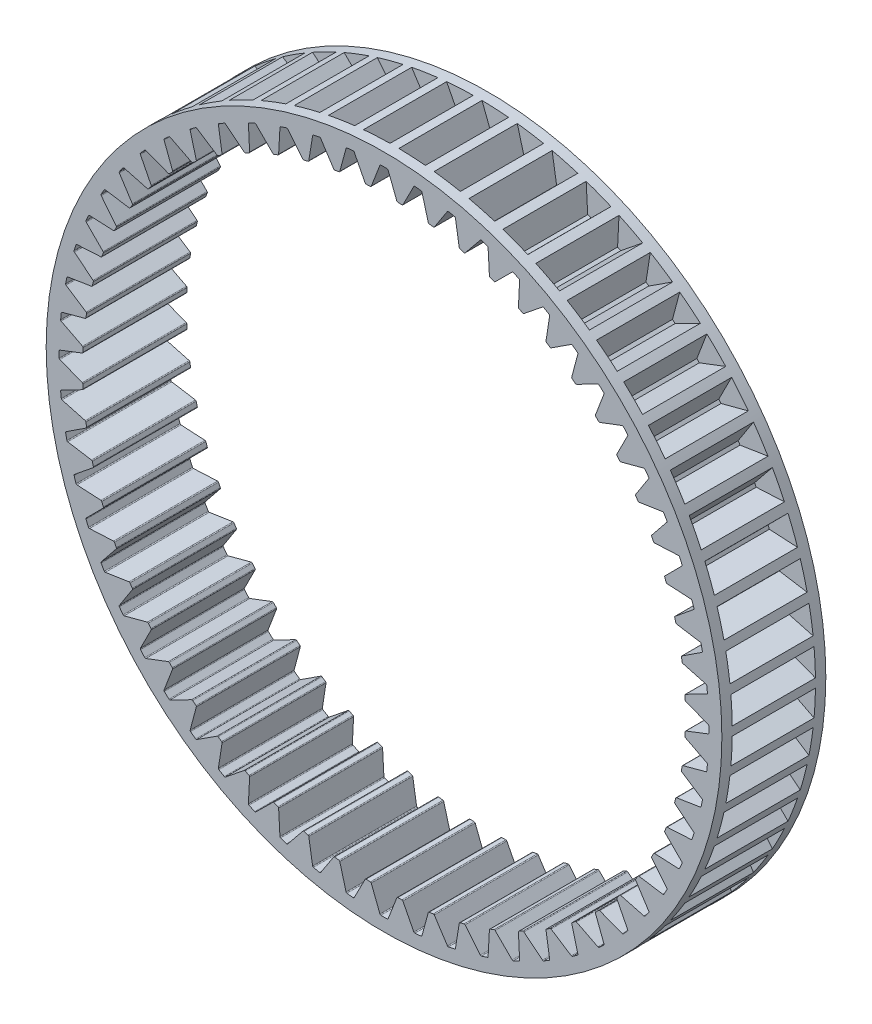
from build123d import *

# Parameters (mm, degrees)
SKETCH1_R           = 32.5
BOSS_EXTRUDE1_DEPTH = 10
CUT_EXTRUDE9_DEPTH  = 8
CIRPATTERN2_COUNT   = 60


with BuildPart() as part:
    # Sketch1 → Boss-Extrude1 (new body)
    with BuildSketch(Plane.XY):
        Circle(SKETCH1_R)
        with BuildLine():
            Line((-1.22642736, 29.033979374), (-0.394405156, 31.184625414))
            ThreePointArc((-0.394405156, 31.184625414), (-0.358072014, 31.230756791), (-0.302108, 31.248539658))
            ThreePointArc((-0.302108, 31.248539658), (0, 31.25), (0.302108, 31.248539658))
            ThreePointArc((0.302108, 31.248539658), (0.358072014, 31.230756791), (0.394405156, 31.184625414))
            Line((0.394405156, 31.184625414), (1.22642736, 29.033979374))
            ThreePointArc((1.22642736, 29.033979374), (1.261302231, 28.988877201), (1.31515624, 28.970163342))
            ThreePointArc((1.31515624, 28.970163342), (1.517742731, 28.960256508), (1.720254978, 28.948933017))
            ThreePointArc((1.720254978, 28.948933017), (1.7757701, 28.961915082), (1.815168384, 29.003124765))
            Line((1.815168384, 29.003124765), (2.867436409, 31.055019338))
            ThreePointArc((2.867436409, 31.055019338), (2.908392556, 31.097100155), (2.96590881, 31.108935773))
            ThreePointArc((2.96590881, 31.108935773), (3.266514477, 31.07880923), (3.56681485, 31.045778003))
            ThreePointArc((3.56681485, 31.045778003), (3.620613472, 31.02224272), (3.651925536, 30.972566208))
            Line((3.651925536, 30.972566208), (4.254586109, 28.74673163))
            ThreePointArc((4.254586109, 28.74673163), (4.284555471, 28.698231114), (4.336158332, 28.673990495))
            ThreePointArc((4.336158332, 28.673990495), (4.536599486, 28.642961877), (4.736818723, 28.610532123))
            ThreePointArc((4.736818723, 28.610532123), (4.793386722, 28.617640161), (4.836876764, 28.654505851))
            Line((4.836876764, 28.654505851), (6.09786174, 30.585167971))
            ThreePointArc((6.09786174, 30.585167971), (6.142992169, 30.622737182), (6.201430501, 30.628495878))
            ThreePointArc((6.201430501, 30.628495878), (6.497240338, 30.567112523), (6.792442931, 30.502872308))
            ThreePointArc((6.792442931, 30.502872308), (6.843486731, 30.473842467), (6.869434655, 30.421165085))
            Line((6.869434655, 30.421165085), (7.236130722, 28.144528679))
            ThreePointArc((7.236130722, 28.144528679), (7.260866225, 28.093161202), (7.309652565, 28.063659408))
            ThreePointArc((7.309652565, 28.063659408), (7.505752308, 28.011848962), (7.70148489, 27.958668253))
            ThreePointArc((7.70148489, 27.958668253), (7.758485997, 27.959824386), (7.805591309, 27.991942174))
            Line((7.805591309, 27.991942174), (9.261477622, 29.780219104))
            ThreePointArc((9.261477622, 29.780219104), (9.310287874, 29.812865092), (9.369008022, 29.812483772))
            ThreePointArc((9.369008022, 29.812483772), (9.656781074, 29.720516134), (9.943651585, 29.62577076))
            ThreePointArc((9.943651585, 29.62577076), (9.991381318, 29.591564418), (10.01168081, 29.536463312))
            Line((10.01168081, 29.536463312), (10.138394773, 27.233968381))
            ThreePointArc((10.138394773, 27.233968381), (10.157625409, 27.180296737), (10.203060715, 27.145856996))
            ThreePointArc((10.203060715, 27.145856996), (10.392670537, 27.073832368), (10.581771978, 27.000483363))
            ThreePointArc((10.581771978, 27.000483363), (10.638581675, 26.995674924), (10.688786162, 27.022692922))
            Line((10.688786162, 27.022692922), (12.323622817, 28.648991924))
            ThreePointArc((12.323622817, 28.648991924), (12.375578116, 28.676357014), (12.433936731, 28.669839856))
            ThreePointArc((12.433936731, 28.669839856), (12.710520096, 28.548295551), (12.985915512, 28.424083069))
            ThreePointArc((12.985915512, 28.424083069), (13.02980824, 28.385074996), (13.044236895, 28.328153866))
            Line((13.044236895, 28.328153866), (12.929580449, 26.025027028))
            ThreePointArc((12.929580449, 26.025027028), (12.943095523, 25.969639253), (12.984681997, 25.930638894))
            ThreePointArc((12.984681997, 25.930638894), (13.165724492, 25.839189201), (13.346122957, 25.746475526))
            ThreePointArc((13.346122957, 25.746475526), (13.402118826, 25.735755199), (13.454872438, 25.757377391))
            Line((13.454872438, 25.757377391), (15.250747822, 27.203880394))
            ThreePointArc((15.250747822, 27.203880394), (15.305278935, 27.225664767), (15.362636627, 27.213083175))
            ThreePointArc((15.362636627, 27.213083175), (15.625, 27.063293868), (15.885903031, 26.910975175))
            ThreePointArc((15.885903031, 26.910975175), (15.925477856, 26.867592754), (15.933877592, 26.809475238))
            Line((15.933877592, 26.809475238), (15.579106936, 24.530950031))
            ThreePointArc((15.579106936, 24.530950031), (15.586758375, 24.474452967), (15.624040385, 24.431319286))
            ThreePointArc((15.624040385, 24.431319286), (15.794532015, 24.32144647), (15.96425102, 24.210383916))
            ThreePointArc((15.96425102, 24.210383916), (16.018819559, 24.193869153), (16.073544315, 24.209858643))
            Line((16.073544315, 24.209858643), (18.010782442, 25.460717457))
            ThreePointArc((18.010782442, 25.460717457), (18.067291916, 25.47668244), (18.123020261, 25.458174259))
            ThreePointArc((18.123020261, 25.458174259), (18.368289134, 25.281781074), (18.611841272, 25.103025006))
            ThreePointArc((18.611841272, 25.103025006), (18.646664604, 25.055743542), (18.648943391, 24.997066389))
            Line((18.648943391, 24.997066389), (18.057945468, 22.768106813))
            ThreePointArc((18.057945468, 22.768106813), (18.059649439, 22.711119453), (18.092218518, 22.664325031))
            ThreePointArc((18.092218518, 22.664325031), (18.25029134, 22.537232882), (18.407471409, 22.409038273))
            ThreePointArc((18.407471409, 22.409038273), (18.460014752, 22.386910015), (18.516111078, 22.397091618))
            Line((18.516111078, 22.397091618), (20.573487161, 23.438601572))
            ThreePointArc((20.573487161, 23.438601572), (20.631355865, 23.448572249), (20.684844293, 23.424340259))
            ThreePointArc((20.684844293, 23.424340259), (20.910331449, 23.223275796), (21.133864286, 23.020040842))
            ThreePointArc((21.133864286, 23.020040842), (21.163554593, 22.969378361), (21.159687463, 22.910784449))
            Line((21.159687463, 22.910784449), (20.33893737, 20.755811452))
            ThreePointArc((20.33893737, 20.755811452), (20.334675206, 20.698958161), (20.362174518, 20.649015688))
            ThreePointArc((20.362174518, 20.649015688), (20.506096654, 20.506096654), (20.649015688, 20.362174518))
            ThreePointArc((20.649015688, 20.362174518), (20.698958161, 20.334675206), (20.755811452, 20.33893737))
            Line((20.755811452, 20.33893737), (22.910784449, 21.159687463))
            ThreePointArc((22.910784449, 21.159687463), (22.969378361, 21.163554593), (23.020040842, 21.133864286))
            ThreePointArc((23.020040842, 21.133864286), (23.223275796, 20.910331449), (23.424340259, 20.684844293))
            ThreePointArc((23.424340259, 20.684844293), (23.448572249, 20.631355865), (23.438601572, 20.573487161))
            Line((23.438601572, 20.573487161), (22.397091618, 18.516111078))
            ThreePointArc((22.397091618, 18.516111078), (22.386910015, 18.460014752), (22.409038273, 18.407471409))
            ThreePointArc((22.409038273, 18.407471409), (22.537232882, 18.25029134), (22.664325031, 18.092218518))
            ThreePointArc((22.664325031, 18.092218518), (22.711119453, 18.059649439), (22.768106813, 18.057945468))
            Line((22.768106813, 18.057945468), (24.997066389, 18.648943391))
            ThreePointArc((24.997066389, 18.648943391), (25.055743542, 18.646664604), (25.103025006, 18.611841272))
            ThreePointArc((25.103025006, 18.611841272), (25.281781074, 18.368289134), (25.458174259, 18.123020261))
            ThreePointArc((25.458174259, 18.123020261), (25.47668244, 18.067291916), (25.460717457, 18.010782442))
            Line((25.460717457, 18.010782442), (24.209858643, 16.073544315))
            ThreePointArc((24.209858643, 16.073544315), (24.193869153, 16.018819559), (24.210383916, 15.96425102))
            ThreePointArc((24.210383916, 15.96425102), (24.32144647, 15.794532015), (24.431319286, 15.624040385))
            ThreePointArc((24.431319286, 15.624040385), (24.474452967, 15.586758375), (24.530950031, 15.579106936))
            Line((24.530950031, 15.579106936), (26.809475238, 15.933877592))
            ThreePointArc((26.809475238, 15.933877592), (26.867592754, 15.925477856), (26.910975175, 15.885903031))
            ThreePointArc((26.910975175, 15.885903031), (27.063293868, 15.625), (27.213083175, 15.362636627))
            ThreePointArc((27.213083175, 15.362636627), (27.225664767, 15.305278935), (27.203880394, 15.250747822))
            Line((27.203880394, 15.250747822), (25.757377391, 13.454872438))
            ThreePointArc((25.757377391, 13.454872438), (25.735755199, 13.402118826), (25.746475526, 13.346122957))
            ThreePointArc((25.746475526, 13.346122957), (25.839189201, 13.165724492), (25.930638894, 12.984681997))
            ThreePointArc((25.930638894, 12.984681997), (25.969639253, 12.943095523), (26.025027028, 12.929580449))
            Line((26.025027028, 12.929580449), (28.328153866, 13.044236895))
            ThreePointArc((28.328153866, 13.044236895), (28.385074996, 13.02980824), (28.424083069, 12.985915512))
            ThreePointArc((28.424083069, 12.985915512), (28.548295551, 12.710520096), (28.669839856, 12.433936731))
            ThreePointArc((28.669839856, 12.433936731), (28.676357014, 12.375578116), (28.648991924, 12.323622817))
            Line((28.648991924, 12.323622817), (27.022692922, 10.688786162))
            ThreePointArc((27.022692922, 10.688786162), (26.995674924, 10.638581675), (27.000483363, 10.581771978))
            ThreePointArc((27.000483363, 10.581771978), (27.073832368, 10.392670537), (27.145856996, 10.203060715))
            ThreePointArc((27.145856996, 10.203060715), (27.180296737, 10.157625409), (27.233968381, 10.138394773))
            Line((27.233968381, 10.138394773), (29.536463312, 10.01168081))
            ThreePointArc((29.536463312, 10.01168081), (29.591564418, 9.991381318), (29.62577076, 9.943651585))
            ThreePointArc((29.62577076, 9.943651585), (29.720516134, 9.656781074), (29.812483772, 9.369008022))
            ThreePointArc((29.812483772, 9.369008022), (29.812865092, 9.310287874), (29.780219104, 9.261477622))
            Line((29.780219104, 9.261477622), (27.991942174, 7.805591309))
            ThreePointArc((27.991942174, 7.805591309), (27.959824386, 7.758485997), (27.958668253, 7.70148489))
            ThreePointArc((27.958668253, 7.70148489), (28.011848962, 7.505752308), (28.063659408, 7.309652565))
            ThreePointArc((28.063659408, 7.309652565), (28.093161202, 7.260866225), (28.144528679, 7.236130722))
            Line((28.144528679, 7.236130722), (30.421165085, 6.869434655))
            ThreePointArc((30.421165085, 6.869434655), (30.473842467, 6.843486731), (30.502872308, 6.792442931))
            ThreePointArc((30.502872308, 6.792442931), (30.567112523, 6.497240338), (30.628495878, 6.201430501))
            ThreePointArc((30.628495878, 6.201430501), (30.622737182, 6.142992169), (30.585167971, 6.09786174))
            Line((30.585167971, 6.09786174), (28.654505851, 4.836876764))
            ThreePointArc((28.654505851, 4.836876764), (28.617640161, 4.793386722), (28.610532123, 4.736818723))
            ThreePointArc((28.610532123, 4.736818723), (28.642961877, 4.536599486), (28.673990495, 4.336158332))
            ThreePointArc((28.673990495, 4.336158332), (28.698231114, 4.284555471), (28.74673163, 4.254586109))
            Line((28.74673163, 4.254586109), (30.972566208, 3.651925536))
            ThreePointArc((30.972566208, 3.651925536), (31.02224272, 3.620613472), (31.045778003, 3.56681485))
            ThreePointArc((31.045778003, 3.56681485), (31.07880923, 3.266514477), (31.108935773, 2.96590881))
            ThreePointArc((31.108935773, 2.96590881), (31.097100155, 2.908392556), (31.055019338, 2.867436409))
            Line((31.055019338, 2.867436409), (29.003124765, 1.815168384))
            ThreePointArc((29.003124765, 1.815168384), (28.961915082, 1.7757701), (28.948933017, 1.720254978))
            ThreePointArc((28.948933017, 1.720254978), (28.960256508, 1.517742731), (28.970163342, 1.31515624))
            ThreePointArc((28.970163342, 1.31515624), (28.988877201, 1.261302231), (29.033979374, 1.22642736))
            Line((29.033979374, 1.22642736), (31.184625414, 0.394405156))
            ThreePointArc((31.184625414, 0.394405156), (31.230756791, 0.358072014), (31.248539658, 0.302108))
            ThreePointArc((31.248539658, 0.302108), (31.25, 0), (31.248539658, -0.302108))
            ThreePointArc((31.248539658, -0.302108), (31.230756791, -0.358072014), (31.184625414, -0.394405156))
            Line((31.184625414, -0.394405156), (29.033979374, -1.22642736))
            ThreePointArc((29.033979374, -1.22642736), (28.988877201, -1.261302231), (28.970163342, -1.31515624))
            ThreePointArc((28.970163342, -1.31515624), (28.960256508, -1.517742731), (28.948933017, -1.720254978))
            ThreePointArc((28.948933017, -1.720254978), (28.961915082, -1.7757701), (29.003124765, -1.815168384))
            Line((29.003124765, -1.815168384), (31.055019338, -2.867436409))
            ThreePointArc((31.055019338, -2.867436409), (31.097100155, -2.908392556), (31.108935773, -2.96590881))
            ThreePointArc((31.108935773, -2.96590881), (31.07880923, -3.266514477), (31.045778003, -3.56681485))
            ThreePointArc((31.045778003, -3.56681485), (31.02224272, -3.620613472), (30.972566208, -3.651925536))
            Line((30.972566208, -3.651925536), (28.74673163, -4.254586109))
            ThreePointArc((28.74673163, -4.254586109), (28.698231114, -4.284555471), (28.673990495, -4.336158332))
            ThreePointArc((28.673990495, -4.336158332), (28.642961877, -4.536599486), (28.610532123, -4.736818723))
            ThreePointArc((28.610532123, -4.736818723), (28.617640161, -4.793386722), (28.654505851, -4.836876764))
            Line((28.654505851, -4.836876764), (30.585167971, -6.09786174))
            ThreePointArc((30.585167971, -6.09786174), (30.622737182, -6.142992169), (30.628495878, -6.201430501))
            ThreePointArc((30.628495878, -6.201430501), (30.567112523, -6.497240338), (30.502872308, -6.792442931))
            ThreePointArc((30.502872308, -6.792442931), (30.473842467, -6.843486731), (30.421165085, -6.869434655))
            Line((30.421165085, -6.869434655), (28.144528679, -7.236130722))
            ThreePointArc((28.144528679, -7.236130722), (28.093161202, -7.260866225), (28.063659408, -7.309652565))
            ThreePointArc((28.063659408, -7.309652565), (28.011848962, -7.505752308), (27.958668253, -7.70148489))
            ThreePointArc((27.958668253, -7.70148489), (27.959824386, -7.758485997), (27.991942174, -7.805591309))
            Line((27.991942174, -7.805591309), (29.780219104, -9.261477622))
            ThreePointArc((29.780219104, -9.261477622), (29.812865092, -9.310287874), (29.812483772, -9.369008022))
            ThreePointArc((29.812483772, -9.369008022), (29.720516134, -9.656781074), (29.62577076, -9.943651585))
            ThreePointArc((29.62577076, -9.943651585), (29.591564418, -9.991381318), (29.536463312, -10.01168081))
            Line((29.536463312, -10.01168081), (27.233968381, -10.138394773))
            ThreePointArc((27.233968381, -10.138394773), (27.180296737, -10.157625409), (27.145856996, -10.203060715))
            ThreePointArc((27.145856996, -10.203060715), (27.073832368, -10.392670537), (27.000483363, -10.581771978))
            ThreePointArc((27.000483363, -10.581771978), (26.995674924, -10.638581675), (27.022692922, -10.688786162))
            Line((27.022692922, -10.688786162), (28.648991924, -12.323622817))
            ThreePointArc((28.648991924, -12.323622817), (28.676357014, -12.375578116), (28.669839856, -12.433936731))
            ThreePointArc((28.669839856, -12.433936731), (28.548295551, -12.710520096), (28.424083069, -12.985915512))
            ThreePointArc((28.424083069, -12.985915512), (28.385074996, -13.02980824), (28.328153866, -13.044236895))
            Line((28.328153866, -13.044236895), (26.025027028, -12.929580449))
            ThreePointArc((26.025027028, -12.929580449), (25.969639253, -12.943095523), (25.930638894, -12.984681997))
            ThreePointArc((25.930638894, -12.984681997), (25.839189201, -13.165724492), (25.746475526, -13.346122957))
            ThreePointArc((25.746475526, -13.346122957), (25.735755199, -13.402118826), (25.757377391, -13.454872438))
            Line((25.757377391, -13.454872438), (27.203880394, -15.250747822))
            ThreePointArc((27.203880394, -15.250747822), (27.225664767, -15.305278935), (27.213083175, -15.362636627))
            ThreePointArc((27.213083175, -15.362636627), (27.063293868, -15.625), (26.910975175, -15.885903031))
            ThreePointArc((26.910975175, -15.885903031), (26.867592754, -15.925477856), (26.809475238, -15.933877592))
            Line((26.809475238, -15.933877592), (24.530950031, -15.579106936))
            ThreePointArc((24.530950031, -15.579106936), (24.474452967, -15.586758375), (24.431319286, -15.624040385))
            ThreePointArc((24.431319286, -15.624040385), (24.32144647, -15.794532015), (24.210383916, -15.96425102))
            ThreePointArc((24.210383916, -15.96425102), (24.193869153, -16.018819559), (24.209858643, -16.073544315))
            Line((24.209858643, -16.073544315), (25.460717457, -18.010782442))
            ThreePointArc((25.460717457, -18.010782442), (25.47668244, -18.067291916), (25.458174259, -18.123020261))
            ThreePointArc((25.458174259, -18.123020261), (25.281781074, -18.368289134), (25.103025006, -18.611841272))
            ThreePointArc((25.103025006, -18.611841272), (25.055743542, -18.646664604), (24.997066389, -18.648943391))
            Line((24.997066389, -18.648943391), (22.768106813, -18.057945468))
            ThreePointArc((22.768106813, -18.057945468), (22.711119453, -18.059649439), (22.664325031, -18.092218518))
            ThreePointArc((22.664325031, -18.092218518), (22.537232882, -18.25029134), (22.409038273, -18.407471409))
            ThreePointArc((22.409038273, -18.407471409), (22.386910015, -18.460014752), (22.397091618, -18.516111078))
            Line((22.397091618, -18.516111078), (23.438601572, -20.573487161))
            ThreePointArc((23.438601572, -20.573487161), (23.448572249, -20.631355865), (23.424340259, -20.684844293))
            ThreePointArc((23.424340259, -20.684844293), (23.223275796, -20.910331449), (23.020040842, -21.133864286))
            ThreePointArc((23.020040842, -21.133864286), (22.969378361, -21.163554593), (22.910784449, -21.159687463))
            Line((22.910784449, -21.159687463), (20.755811452, -20.33893737))
            ThreePointArc((20.755811452, -20.33893737), (20.698958161, -20.334675206), (20.649015688, -20.362174518))
            ThreePointArc((20.649015688, -20.362174518), (20.506096654, -20.506096654), (20.362174518, -20.649015688))
            ThreePointArc((20.362174518, -20.649015688), (20.334675206, -20.698958161), (20.33893737, -20.755811452))
            Line((20.33893737, -20.755811452), (21.159687463, -22.910784449))
            ThreePointArc((21.159687463, -22.910784449), (21.163554593, -22.969378361), (21.133864286, -23.020040842))
            ThreePointArc((21.133864286, -23.020040842), (20.910331449, -23.223275796), (20.684844293, -23.424340259))
            ThreePointArc((20.684844293, -23.424340259), (20.631355865, -23.448572249), (20.573487161, -23.438601572))
            Line((20.573487161, -23.438601572), (18.516111078, -22.397091618))
            ThreePointArc((18.516111078, -22.397091618), (18.460014752, -22.386910015), (18.407471409, -22.409038273))
            ThreePointArc((18.407471409, -22.409038273), (18.25029134, -22.537232882), (18.092218518, -22.664325031))
            ThreePointArc((18.092218518, -22.664325031), (18.059649439, -22.711119453), (18.057945468, -22.768106813))
            Line((18.057945468, -22.768106813), (18.648943391, -24.997066389))
            ThreePointArc((18.648943391, -24.997066389), (18.646664604, -25.055743542), (18.611841272, -25.103025006))
            ThreePointArc((18.611841272, -25.103025006), (18.368289134, -25.281781074), (18.123020261, -25.458174259))
            ThreePointArc((18.123020261, -25.458174259), (18.067291916, -25.47668244), (18.010782442, -25.460717457))
            Line((18.010782442, -25.460717457), (16.073544315, -24.209858643))
            ThreePointArc((16.073544315, -24.209858643), (16.018819559, -24.193869153), (15.96425102, -24.210383916))
            ThreePointArc((15.96425102, -24.210383916), (15.794532015, -24.32144647), (15.624040385, -24.431319286))
            ThreePointArc((15.624040385, -24.431319286), (15.586758375, -24.474452967), (15.579106936, -24.530950031))
            Line((15.579106936, -24.530950031), (15.933877592, -26.809475238))
            ThreePointArc((15.933877592, -26.809475238), (15.925477856, -26.867592754), (15.885903031, -26.910975175))
            ThreePointArc((15.885903031, -26.910975175), (15.625, -27.063293868), (15.362636627, -27.213083175))
            ThreePointArc((15.362636627, -27.213083175), (15.305278935, -27.225664767), (15.250747822, -27.203880394))
            Line((15.250747822, -27.203880394), (13.454872438, -25.757377391))
            ThreePointArc((13.454872438, -25.757377391), (13.402118826, -25.735755199), (13.346122957, -25.746475526))
            ThreePointArc((13.346122957, -25.746475526), (13.165724492, -25.839189201), (12.984681997, -25.930638894))
            ThreePointArc((12.984681997, -25.930638894), (12.943095523, -25.969639253), (12.929580449, -26.025027028))
            Line((12.929580449, -26.025027028), (13.044236895, -28.328153866))
            ThreePointArc((13.044236895, -28.328153866), (13.02980824, -28.385074996), (12.985915512, -28.424083069))
            ThreePointArc((12.985915512, -28.424083069), (12.710520096, -28.548295551), (12.433936731, -28.669839856))
            ThreePointArc((12.433936731, -28.669839856), (12.375578116, -28.676357014), (12.323622817, -28.648991924))
            Line((12.323622817, -28.648991924), (10.688786162, -27.022692922))
            ThreePointArc((10.688786162, -27.022692922), (10.638581675, -26.995674924), (10.581771978, -27.000483363))
            ThreePointArc((10.581771978, -27.000483363), (10.392670537, -27.073832368), (10.203060715, -27.145856996))
            ThreePointArc((10.203060715, -27.145856996), (10.157625409, -27.180296737), (10.138394773, -27.233968381))
            Line((10.138394773, -27.233968381), (10.01168081, -29.536463312))
            ThreePointArc((10.01168081, -29.536463312), (9.991381318, -29.591564418), (9.943651585, -29.62577076))
            ThreePointArc((9.943651585, -29.62577076), (9.656781074, -29.720516134), (9.369008022, -29.812483772))
            ThreePointArc((9.369008022, -29.812483772), (9.310287874, -29.812865092), (9.261477622, -29.780219104))
            Line((9.261477622, -29.780219104), (7.805591309, -27.991942174))
            ThreePointArc((7.805591309, -27.991942174), (7.758485997, -27.959824386), (7.70148489, -27.958668253))
            ThreePointArc((7.70148489, -27.958668253), (7.505752308, -28.011848962), (7.309652565, -28.063659408))
            ThreePointArc((7.309652565, -28.063659408), (7.260866225, -28.093161202), (7.236130722, -28.144528679))
            Line((7.236130722, -28.144528679), (6.869434655, -30.421165085))
            ThreePointArc((6.869434655, -30.421165085), (6.843486731, -30.473842467), (6.792442931, -30.502872308))
            ThreePointArc((6.792442931, -30.502872308), (6.497240338, -30.567112523), (6.201430501, -30.628495878))
            ThreePointArc((6.201430501, -30.628495878), (6.142992169, -30.622737182), (6.09786174, -30.585167971))
            Line((6.09786174, -30.585167971), (4.836876764, -28.654505851))
            ThreePointArc((4.836876764, -28.654505851), (4.793386722, -28.617640161), (4.736818723, -28.610532123))
            ThreePointArc((4.736818723, -28.610532123), (4.536599486, -28.642961877), (4.336158332, -28.673990495))
            ThreePointArc((4.336158332, -28.673990495), (4.284555471, -28.698231114), (4.254586109, -28.74673163))
            Line((4.254586109, -28.74673163), (3.651925536, -30.972566208))
            ThreePointArc((3.651925536, -30.972566208), (3.620613472, -31.02224272), (3.56681485, -31.045778003))
            ThreePointArc((3.56681485, -31.045778003), (3.266514477, -31.07880923), (2.96590881, -31.108935773))
            ThreePointArc((2.96590881, -31.108935773), (2.908392556, -31.097100155), (2.867436409, -31.055019338))
            Line((2.867436409, -31.055019338), (1.815168384, -29.003124765))
            ThreePointArc((1.815168384, -29.003124765), (1.7757701, -28.961915082), (1.720254978, -28.948933017))
            ThreePointArc((1.720254978, -28.948933017), (1.517742731, -28.960256508), (1.31515624, -28.970163342))
            ThreePointArc((1.31515624, -28.970163342), (1.261302231, -28.988877201), (1.22642736, -29.033979374))
            Line((1.22642736, -29.033979374), (0.394405156, -31.184625414))
            ThreePointArc((0.394405156, -31.184625414), (0.358072014, -31.230756791), (0.302108, -31.248539658))
            ThreePointArc((0.302108, -31.248539658), (0, -31.25), (-0.302108, -31.248539658))
            ThreePointArc((-0.302108, -31.248539658), (-0.358072014, -31.230756791), (-0.394405156, -31.184625414))
            Line((-0.394405156, -31.184625414), (-1.22642736, -29.033979374))
            ThreePointArc((-1.22642736, -29.033979374), (-1.261302231, -28.988877201), (-1.31515624, -28.970163342))
            ThreePointArc((-1.31515624, -28.970163342), (-1.517742731, -28.960256508), (-1.720254978, -28.948933017))
            ThreePointArc((-1.720254978, -28.948933017), (-1.7757701, -28.961915082), (-1.815168384, -29.003124765))
            Line((-1.815168384, -29.003124765), (-2.867436409, -31.055019338))
            ThreePointArc((-2.867436409, -31.055019338), (-2.908392556, -31.097100155), (-2.96590881, -31.108935773))
            ThreePointArc((-2.96590881, -31.108935773), (-3.266514477, -31.07880923), (-3.56681485, -31.045778003))
            ThreePointArc((-3.56681485, -31.045778003), (-3.620613472, -31.02224272), (-3.651925536, -30.972566208))
            Line((-3.651925536, -30.972566208), (-4.254586109, -28.74673163))
            ThreePointArc((-4.254586109, -28.74673163), (-4.284555471, -28.698231114), (-4.336158332, -28.673990495))
            ThreePointArc((-4.336158332, -28.673990495), (-4.536599486, -28.642961877), (-4.736818723, -28.610532123))
            ThreePointArc((-4.736818723, -28.610532123), (-4.793386722, -28.617640161), (-4.836876764, -28.654505851))
            Line((-4.836876764, -28.654505851), (-6.09786174, -30.585167971))
            ThreePointArc((-6.09786174, -30.585167971), (-6.142992169, -30.622737182), (-6.201430501, -30.628495878))
            ThreePointArc((-6.201430501, -30.628495878), (-6.497240338, -30.567112523), (-6.792442931, -30.502872308))
            ThreePointArc((-6.792442931, -30.502872308), (-6.843486731, -30.473842467), (-6.869434655, -30.421165085))
            Line((-6.869434655, -30.421165085), (-7.236130722, -28.144528679))
            ThreePointArc((-7.236130722, -28.144528679), (-7.260866225, -28.093161202), (-7.309652565, -28.063659408))
            ThreePointArc((-7.309652565, -28.063659408), (-7.505752308, -28.011848962), (-7.70148489, -27.958668253))
            ThreePointArc((-7.70148489, -27.958668253), (-7.758485997, -27.959824386), (-7.805591309, -27.991942174))
            Line((-7.805591309, -27.991942174), (-9.261477622, -29.780219104))
            ThreePointArc((-9.261477622, -29.780219104), (-9.310287874, -29.812865092), (-9.369008022, -29.812483772))
            ThreePointArc((-9.369008022, -29.812483772), (-9.656781074, -29.720516134), (-9.943651585, -29.62577076))
            ThreePointArc((-9.943651585, -29.62577076), (-9.991381318, -29.591564418), (-10.01168081, -29.536463312))
            Line((-10.01168081, -29.536463312), (-10.138394773, -27.233968381))
            ThreePointArc((-10.138394773, -27.233968381), (-10.157625409, -27.180296737), (-10.203060715, -27.145856996))
            ThreePointArc((-10.203060715, -27.145856996), (-10.392670537, -27.073832368), (-10.581771978, -27.000483363))
            ThreePointArc((-10.581771978, -27.000483363), (-10.638581675, -26.995674924), (-10.688786162, -27.022692922))
            Line((-10.688786162, -27.022692922), (-12.323622817, -28.648991924))
            ThreePointArc((-12.323622817, -28.648991924), (-12.375578116, -28.676357014), (-12.433936731, -28.669839856))
            ThreePointArc((-12.433936731, -28.669839856), (-12.710520096, -28.548295551), (-12.985915512, -28.424083069))
            ThreePointArc((-12.985915512, -28.424083069), (-13.02980824, -28.385074996), (-13.044236895, -28.328153866))
            Line((-13.044236895, -28.328153866), (-12.929580449, -26.025027028))
            ThreePointArc((-12.929580449, -26.025027028), (-12.943095523, -25.969639253), (-12.984681997, -25.930638894))
            ThreePointArc((-12.984681997, -25.930638894), (-13.165724492, -25.839189201), (-13.346122957, -25.746475526))
            ThreePointArc((-13.346122957, -25.746475526), (-13.402118826, -25.735755199), (-13.454872438, -25.757377391))
            Line((-13.454872438, -25.757377391), (-15.250747822, -27.203880394))
            ThreePointArc((-15.250747822, -27.203880394), (-15.305278935, -27.225664767), (-15.362636627, -27.213083175))
            ThreePointArc((-15.362636627, -27.213083175), (-15.625, -27.063293868), (-15.885903031, -26.910975175))
            ThreePointArc((-15.885903031, -26.910975175), (-15.925477856, -26.867592754), (-15.933877592, -26.809475238))
            Line((-15.933877592, -26.809475238), (-15.579106936, -24.530950031))
            ThreePointArc((-15.579106936, -24.530950031), (-15.586758375, -24.474452967), (-15.624040385, -24.431319286))
            ThreePointArc((-15.624040385, -24.431319286), (-15.794532015, -24.32144647), (-15.96425102, -24.210383916))
            ThreePointArc((-15.96425102, -24.210383916), (-16.018819559, -24.193869153), (-16.073544315, -24.209858643))
            Line((-16.073544315, -24.209858643), (-18.010782442, -25.460717457))
            ThreePointArc((-18.010782442, -25.460717457), (-18.067291916, -25.47668244), (-18.123020261, -25.458174259))
            ThreePointArc((-18.123020261, -25.458174259), (-18.368289134, -25.281781074), (-18.611841272, -25.103025006))
            ThreePointArc((-18.611841272, -25.103025006), (-18.646664604, -25.055743542), (-18.648943391, -24.997066389))
            Line((-18.648943391, -24.997066389), (-18.057945468, -22.768106813))
            ThreePointArc((-18.057945468, -22.768106813), (-18.059649439, -22.711119453), (-18.092218518, -22.664325031))
            ThreePointArc((-18.092218518, -22.664325031), (-18.25029134, -22.537232882), (-18.407471409, -22.409038273))
            ThreePointArc((-18.407471409, -22.409038273), (-18.460014752, -22.386910015), (-18.516111078, -22.397091618))
            Line((-18.516111078, -22.397091618), (-20.573487161, -23.438601572))
            ThreePointArc((-20.573487161, -23.438601572), (-20.631355865, -23.448572249), (-20.684844293, -23.424340259))
            ThreePointArc((-20.684844293, -23.424340259), (-20.910331449, -23.223275796), (-21.133864286, -23.020040842))
            ThreePointArc((-21.133864286, -23.020040842), (-21.163554593, -22.969378361), (-21.159687463, -22.910784449))
            Line((-21.159687463, -22.910784449), (-20.33893737, -20.755811452))
            ThreePointArc((-20.33893737, -20.755811452), (-20.334675206, -20.698958161), (-20.362174518, -20.649015688))
            ThreePointArc((-20.362174518, -20.649015688), (-20.506096654, -20.506096654), (-20.649015688, -20.362174518))
            ThreePointArc((-20.649015688, -20.362174518), (-20.698958161, -20.334675206), (-20.755811452, -20.33893737))
            Line((-20.755811452, -20.33893737), (-22.910784449, -21.159687463))
            ThreePointArc((-22.910784449, -21.159687463), (-22.969378361, -21.163554593), (-23.020040842, -21.133864286))
            ThreePointArc((-23.020040842, -21.133864286), (-23.223275796, -20.910331449), (-23.424340259, -20.684844293))
            ThreePointArc((-23.424340259, -20.684844293), (-23.448572249, -20.631355865), (-23.438601572, -20.573487161))
            Line((-23.438601572, -20.573487161), (-22.397091618, -18.516111078))
            ThreePointArc((-22.397091618, -18.516111078), (-22.386910015, -18.460014752), (-22.409038273, -18.407471409))
            ThreePointArc((-22.409038273, -18.407471409), (-22.537232882, -18.25029134), (-22.664325031, -18.092218518))
            ThreePointArc((-22.664325031, -18.092218518), (-22.711119453, -18.059649439), (-22.768106813, -18.057945468))
            Line((-22.768106813, -18.057945468), (-24.997066389, -18.648943391))
            ThreePointArc((-24.997066389, -18.648943391), (-25.055743542, -18.646664604), (-25.103025006, -18.611841272))
            ThreePointArc((-25.103025006, -18.611841272), (-25.281781074, -18.368289134), (-25.458174259, -18.123020261))
            ThreePointArc((-25.458174259, -18.123020261), (-25.47668244, -18.067291916), (-25.460717457, -18.010782442))
            Line((-25.460717457, -18.010782442), (-24.209858643, -16.073544315))
            ThreePointArc((-24.209858643, -16.073544315), (-24.193869153, -16.018819559), (-24.210383916, -15.96425102))
            ThreePointArc((-24.210383916, -15.96425102), (-24.32144647, -15.794532015), (-24.431319286, -15.624040385))
            ThreePointArc((-24.431319286, -15.624040385), (-24.474452967, -15.586758375), (-24.530950031, -15.579106936))
            Line((-24.530950031, -15.579106936), (-26.809475238, -15.933877592))
            ThreePointArc((-26.809475238, -15.933877592), (-26.867592754, -15.925477856), (-26.910975175, -15.885903031))
            ThreePointArc((-26.910975175, -15.885903031), (-27.063293868, -15.625), (-27.213083175, -15.362636627))
            ThreePointArc((-27.213083175, -15.362636627), (-27.225664767, -15.305278935), (-27.203880394, -15.250747822))
            Line((-27.203880394, -15.250747822), (-25.757377391, -13.454872438))
            ThreePointArc((-25.757377391, -13.454872438), (-25.735755199, -13.402118826), (-25.746475526, -13.346122957))
            ThreePointArc((-25.746475526, -13.346122957), (-25.839189201, -13.165724492), (-25.930638894, -12.984681997))
            ThreePointArc((-25.930638894, -12.984681997), (-25.969639253, -12.943095523), (-26.025027028, -12.929580449))
            Line((-26.025027028, -12.929580449), (-28.328153866, -13.044236895))
            ThreePointArc((-28.328153866, -13.044236895), (-28.385074996, -13.02980824), (-28.424083069, -12.985915512))
            ThreePointArc((-28.424083069, -12.985915512), (-28.548295551, -12.710520096), (-28.669839856, -12.433936731))
            ThreePointArc((-28.669839856, -12.433936731), (-28.676357014, -12.375578116), (-28.648991924, -12.323622817))
            Line((-28.648991924, -12.323622817), (-27.022692922, -10.688786162))
            ThreePointArc((-27.022692922, -10.688786162), (-26.995674924, -10.638581675), (-27.000483363, -10.581771978))
            ThreePointArc((-27.000483363, -10.581771978), (-27.073832368, -10.392670537), (-27.145856996, -10.203060715))
            ThreePointArc((-27.145856996, -10.203060715), (-27.180296737, -10.157625409), (-27.233968381, -10.138394773))
            Line((-27.233968381, -10.138394773), (-29.536463312, -10.01168081))
            ThreePointArc((-29.536463312, -10.01168081), (-29.591564418, -9.991381318), (-29.62577076, -9.943651585))
            ThreePointArc((-29.62577076, -9.943651585), (-29.720516134, -9.656781074), (-29.812483772, -9.369008022))
            ThreePointArc((-29.812483772, -9.369008022), (-29.812865092, -9.310287874), (-29.780219104, -9.261477622))
            Line((-29.780219104, -9.261477622), (-27.991942174, -7.805591309))
            ThreePointArc((-27.991942174, -7.805591309), (-27.959824386, -7.758485997), (-27.958668253, -7.70148489))
            ThreePointArc((-27.958668253, -7.70148489), (-28.011848962, -7.505752308), (-28.063659408, -7.309652565))
            ThreePointArc((-28.063659408, -7.309652565), (-28.093161202, -7.260866225), (-28.144528679, -7.236130722))
            Line((-28.144528679, -7.236130722), (-30.421165085, -6.869434655))
            ThreePointArc((-30.421165085, -6.869434655), (-30.473842467, -6.843486731), (-30.502872308, -6.792442931))
            ThreePointArc((-30.502872308, -6.792442931), (-30.567112523, -6.497240338), (-30.628495878, -6.201430501))
            ThreePointArc((-30.628495878, -6.201430501), (-30.622737182, -6.142992169), (-30.585167971, -6.09786174))
            Line((-30.585167971, -6.09786174), (-28.654505851, -4.836876764))
            ThreePointArc((-28.654505851, -4.836876764), (-28.617640161, -4.793386722), (-28.610532123, -4.736818723))
            ThreePointArc((-28.610532123, -4.736818723), (-28.642961877, -4.536599486), (-28.673990495, -4.336158332))
            ThreePointArc((-28.673990495, -4.336158332), (-28.698231114, -4.284555471), (-28.74673163, -4.254586109))
            Line((-28.74673163, -4.254586109), (-30.972566208, -3.651925536))
            ThreePointArc((-30.972566208, -3.651925536), (-31.02224272, -3.620613472), (-31.045778003, -3.56681485))
            ThreePointArc((-31.045778003, -3.56681485), (-31.07880923, -3.266514477), (-31.108935773, -2.96590881))
            ThreePointArc((-31.108935773, -2.96590881), (-31.097100155, -2.908392556), (-31.055019338, -2.867436409))
            Line((-31.055019338, -2.867436409), (-29.003124765, -1.815168384))
            ThreePointArc((-29.003124765, -1.815168384), (-28.961915082, -1.7757701), (-28.948933017, -1.720254978))
            ThreePointArc((-28.948933017, -1.720254978), (-28.960256508, -1.517742731), (-28.970163342, -1.31515624))
            ThreePointArc((-28.970163342, -1.31515624), (-28.988877201, -1.261302231), (-29.033979374, -1.22642736))
            Line((-29.033979374, -1.22642736), (-31.184625414, -0.394405156))
            ThreePointArc((-31.184625414, -0.394405156), (-31.230756791, -0.358072014), (-31.248539658, -0.302108))
            ThreePointArc((-31.248539658, -0.302108), (-31.25, 0), (-31.248539658, 0.302108))
            ThreePointArc((-31.248539658, 0.302108), (-31.230756791, 0.358072014), (-31.184625414, 0.394405156))
            Line((-31.184625414, 0.394405156), (-29.033979374, 1.22642736))
            ThreePointArc((-29.033979374, 1.22642736), (-28.988877201, 1.261302231), (-28.970163342, 1.31515624))
            ThreePointArc((-28.970163342, 1.31515624), (-28.960256508, 1.517742731), (-28.948933017, 1.720254978))
            ThreePointArc((-28.948933017, 1.720254978), (-28.961915082, 1.7757701), (-29.003124765, 1.815168384))
            Line((-29.003124765, 1.815168384), (-31.055019338, 2.867436409))
            ThreePointArc((-31.055019338, 2.867436409), (-31.097100155, 2.908392556), (-31.108935773, 2.96590881))
            ThreePointArc((-31.108935773, 2.96590881), (-31.07880923, 3.266514477), (-31.045778003, 3.56681485))
            ThreePointArc((-31.045778003, 3.56681485), (-31.02224272, 3.620613472), (-30.972566208, 3.651925536))
            Line((-30.972566208, 3.651925536), (-28.74673163, 4.254586109))
            ThreePointArc((-28.74673163, 4.254586109), (-28.698231114, 4.284555471), (-28.673990495, 4.336158332))
            ThreePointArc((-28.673990495, 4.336158332), (-28.642961877, 4.536599486), (-28.610532123, 4.736818723))
            ThreePointArc((-28.610532123, 4.736818723), (-28.617640161, 4.793386722), (-28.654505851, 4.836876764))
            Line((-28.654505851, 4.836876764), (-30.585167971, 6.09786174))
            ThreePointArc((-30.585167971, 6.09786174), (-30.622737182, 6.142992169), (-30.628495878, 6.201430501))
            ThreePointArc((-30.628495878, 6.201430501), (-30.567112523, 6.497240338), (-30.502872308, 6.792442931))
            ThreePointArc((-30.502872308, 6.792442931), (-30.473842467, 6.843486731), (-30.421165085, 6.869434655))
            Line((-30.421165085, 6.869434655), (-28.144528679, 7.236130722))
            ThreePointArc((-28.144528679, 7.236130722), (-28.093161202, 7.260866225), (-28.063659408, 7.309652565))
            ThreePointArc((-28.063659408, 7.309652565), (-28.011848962, 7.505752308), (-27.958668253, 7.70148489))
            ThreePointArc((-27.958668253, 7.70148489), (-27.959824386, 7.758485997), (-27.991942174, 7.805591309))
            Line((-27.991942174, 7.805591309), (-29.780219104, 9.261477622))
            ThreePointArc((-29.780219104, 9.261477622), (-29.812865092, 9.310287874), (-29.812483772, 9.369008022))
            ThreePointArc((-29.812483772, 9.369008022), (-29.720516134, 9.656781074), (-29.62577076, 9.943651585))
            ThreePointArc((-29.62577076, 9.943651585), (-29.591564418, 9.991381318), (-29.536463312, 10.01168081))
            Line((-29.536463312, 10.01168081), (-27.233968381, 10.138394773))
            ThreePointArc((-27.233968381, 10.138394773), (-27.180296737, 10.157625409), (-27.145856996, 10.203060715))
            ThreePointArc((-27.145856996, 10.203060715), (-27.073832368, 10.392670537), (-27.000483363, 10.581771978))
            ThreePointArc((-27.000483363, 10.581771978), (-26.995674924, 10.638581675), (-27.022692922, 10.688786162))
            Line((-27.022692922, 10.688786162), (-28.648991924, 12.323622817))
            ThreePointArc((-28.648991924, 12.323622817), (-28.676357014, 12.375578116), (-28.669839856, 12.433936731))
            ThreePointArc((-28.669839856, 12.433936731), (-28.548295551, 12.710520096), (-28.424083069, 12.985915512))
            ThreePointArc((-28.424083069, 12.985915512), (-28.385074996, 13.02980824), (-28.328153866, 13.044236895))
            Line((-28.328153866, 13.044236895), (-26.025027028, 12.929580449))
            ThreePointArc((-26.025027028, 12.929580449), (-25.969639253, 12.943095523), (-25.930638894, 12.984681997))
            ThreePointArc((-25.930638894, 12.984681997), (-25.839189201, 13.165724492), (-25.746475526, 13.346122957))
            ThreePointArc((-25.746475526, 13.346122957), (-25.735755199, 13.402118826), (-25.757377391, 13.454872438))
            Line((-25.757377391, 13.454872438), (-27.203880394, 15.250747822))
            ThreePointArc((-27.203880394, 15.250747822), (-27.225664767, 15.305278935), (-27.213083175, 15.362636627))
            ThreePointArc((-27.213083175, 15.362636627), (-27.063293868, 15.625), (-26.910975175, 15.885903031))
            ThreePointArc((-26.910975175, 15.885903031), (-26.867592754, 15.925477856), (-26.809475238, 15.933877592))
            Line((-26.809475238, 15.933877592), (-24.530950031, 15.579106936))
            ThreePointArc((-24.530950031, 15.579106936), (-24.474452967, 15.586758375), (-24.431319286, 15.624040385))
            ThreePointArc((-24.431319286, 15.624040385), (-24.32144647, 15.794532015), (-24.210383916, 15.96425102))
            ThreePointArc((-24.210383916, 15.96425102), (-24.193869153, 16.018819559), (-24.209858643, 16.073544315))
            Line((-24.209858643, 16.073544315), (-25.460717457, 18.010782442))
            ThreePointArc((-25.460717457, 18.010782442), (-25.47668244, 18.067291916), (-25.458174259, 18.123020261))
            ThreePointArc((-25.458174259, 18.123020261), (-25.281781074, 18.368289134), (-25.103025006, 18.611841272))
            ThreePointArc((-25.103025006, 18.611841272), (-25.055743542, 18.646664604), (-24.997066389, 18.648943391))
            Line((-24.997066389, 18.648943391), (-22.768106813, 18.057945468))
            ThreePointArc((-22.768106813, 18.057945468), (-22.711119453, 18.059649439), (-22.664325031, 18.092218518))
            ThreePointArc((-22.664325031, 18.092218518), (-22.537232882, 18.25029134), (-22.409038273, 18.407471409))
            ThreePointArc((-22.409038273, 18.407471409), (-22.386910015, 18.460014752), (-22.397091618, 18.516111078))
            Line((-22.397091618, 18.516111078), (-23.438601572, 20.573487161))
            ThreePointArc((-23.438601572, 20.573487161), (-23.448572249, 20.631355865), (-23.424340259, 20.684844293))
            ThreePointArc((-23.424340259, 20.684844293), (-23.223275796, 20.910331449), (-23.020040842, 21.133864286))
            ThreePointArc((-23.020040842, 21.133864286), (-22.969378361, 21.163554593), (-22.910784449, 21.159687463))
            Line((-22.910784449, 21.159687463), (-20.755811452, 20.33893737))
            ThreePointArc((-20.755811452, 20.33893737), (-20.698958161, 20.334675206), (-20.649015688, 20.362174518))
            ThreePointArc((-20.649015688, 20.362174518), (-20.506096654, 20.506096654), (-20.362174518, 20.649015688))
            ThreePointArc((-20.362174518, 20.649015688), (-20.334675206, 20.698958161), (-20.33893737, 20.755811452))
            Line((-20.33893737, 20.755811452), (-21.159687463, 22.910784449))
            ThreePointArc((-21.159687463, 22.910784449), (-21.163554593, 22.969378361), (-21.133864286, 23.020040842))
            ThreePointArc((-21.133864286, 23.020040842), (-20.910331449, 23.223275796), (-20.684844293, 23.424340259))
            ThreePointArc((-20.684844293, 23.424340259), (-20.631355865, 23.448572249), (-20.573487161, 23.438601572))
            Line((-20.573487161, 23.438601572), (-18.516111078, 22.397091618))
            ThreePointArc((-18.516111078, 22.397091618), (-18.460014752, 22.386910015), (-18.407471409, 22.409038273))
            ThreePointArc((-18.407471409, 22.409038273), (-18.25029134, 22.537232882), (-18.092218518, 22.664325031))
            ThreePointArc((-18.092218518, 22.664325031), (-18.059649439, 22.711119453), (-18.057945468, 22.768106813))
            Line((-18.057945468, 22.768106813), (-18.648943391, 24.997066389))
            ThreePointArc((-18.648943391, 24.997066389), (-18.646664604, 25.055743542), (-18.611841272, 25.103025006))
            ThreePointArc((-18.611841272, 25.103025006), (-18.368289134, 25.281781074), (-18.123020261, 25.458174259))
            ThreePointArc((-18.123020261, 25.458174259), (-18.067291916, 25.47668244), (-18.010782442, 25.460717457))
            Line((-18.010782442, 25.460717457), (-16.073544315, 24.209858643))
            ThreePointArc((-16.073544315, 24.209858643), (-16.018819559, 24.193869153), (-15.96425102, 24.210383916))
            ThreePointArc((-15.96425102, 24.210383916), (-15.794532015, 24.32144647), (-15.624040385, 24.431319286))
            ThreePointArc((-15.624040385, 24.431319286), (-15.586758375, 24.474452967), (-15.579106936, 24.530950031))
            Line((-15.579106936, 24.530950031), (-15.933877592, 26.809475238))
            ThreePointArc((-15.933877592, 26.809475238), (-15.925477856, 26.867592754), (-15.885903031, 26.910975175))
            ThreePointArc((-15.885903031, 26.910975175), (-15.625, 27.063293868), (-15.362636627, 27.213083175))
            ThreePointArc((-15.362636627, 27.213083175), (-15.305278935, 27.225664767), (-15.250747822, 27.203880394))
            Line((-15.250747822, 27.203880394), (-13.454872438, 25.757377391))
            ThreePointArc((-13.454872438, 25.757377391), (-13.402118826, 25.735755199), (-13.346122957, 25.746475526))
            ThreePointArc((-13.346122957, 25.746475526), (-13.165724492, 25.839189201), (-12.984681997, 25.930638894))
            ThreePointArc((-12.984681997, 25.930638894), (-12.943095523, 25.969639253), (-12.929580449, 26.025027028))
            Line((-12.929580449, 26.025027028), (-13.044236895, 28.328153866))
            ThreePointArc((-13.044236895, 28.328153866), (-13.02980824, 28.385074996), (-12.985915512, 28.424083069))
            ThreePointArc((-12.985915512, 28.424083069), (-12.710520096, 28.548295551), (-12.433936731, 28.669839856))
            ThreePointArc((-12.433936731, 28.669839856), (-12.375578116, 28.676357014), (-12.323622817, 28.648991924))
            Line((-12.323622817, 28.648991924), (-10.688786162, 27.022692922))
            ThreePointArc((-10.688786162, 27.022692922), (-10.638581675, 26.995674924), (-10.581771978, 27.000483363))
            ThreePointArc((-10.581771978, 27.000483363), (-10.392670537, 27.073832368), (-10.203060715, 27.145856996))
            ThreePointArc((-10.203060715, 27.145856996), (-10.157625409, 27.180296737), (-10.138394773, 27.233968381))
            Line((-10.138394773, 27.233968381), (-10.01168081, 29.536463312))
            ThreePointArc((-10.01168081, 29.536463312), (-9.991381318, 29.591564418), (-9.943651585, 29.62577076))
            ThreePointArc((-9.943651585, 29.62577076), (-9.656781074, 29.720516134), (-9.369008022, 29.812483772))
            ThreePointArc((-9.369008022, 29.812483772), (-9.310287874, 29.812865092), (-9.261477622, 29.780219104))
            Line((-9.261477622, 29.780219104), (-7.805591309, 27.991942174))
            ThreePointArc((-7.805591309, 27.991942174), (-7.758485997, 27.959824386), (-7.70148489, 27.958668253))
            ThreePointArc((-7.70148489, 27.958668253), (-7.505752308, 28.011848962), (-7.309652565, 28.063659408))
            ThreePointArc((-7.309652565, 28.063659408), (-7.260866225, 28.093161202), (-7.236130722, 28.144528679))
            Line((-7.236130722, 28.144528679), (-6.869434655, 30.421165085))
            ThreePointArc((-6.869434655, 30.421165085), (-6.843486731, 30.473842467), (-6.792442931, 30.502872308))
            ThreePointArc((-6.792442931, 30.502872308), (-6.497240338, 30.567112523), (-6.201430501, 30.628495878))
            ThreePointArc((-6.201430501, 30.628495878), (-6.142992169, 30.622737182), (-6.09786174, 30.585167971))
            Line((-6.09786174, 30.585167971), (-4.836876764, 28.654505851))
            ThreePointArc((-4.836876764, 28.654505851), (-4.793386722, 28.617640161), (-4.736818723, 28.610532123))
            ThreePointArc((-4.736818723, 28.610532123), (-4.536599486, 28.642961877), (-4.336158332, 28.673990495))
            ThreePointArc((-4.336158332, 28.673990495), (-4.284555471, 28.698231114), (-4.254586109, 28.74673163))
            Line((-4.254586109, 28.74673163), (-3.651925536, 30.972566208))
            ThreePointArc((-3.651925536, 30.972566208), (-3.620613472, 31.02224272), (-3.56681485, 31.045778003))
            ThreePointArc((-3.56681485, 31.045778003), (-3.266514477, 31.07880923), (-2.96590881, 31.108935773))
            ThreePointArc((-2.96590881, 31.108935773), (-2.908392556, 31.097100155), (-2.867436409, 31.055019338))
            Line((-2.867436409, 31.055019338), (-1.815168384, 29.003124765))
            ThreePointArc((-1.815168384, 29.003124765), (-1.7757701, 28.961915082), (-1.720254978, 28.948933017))
            ThreePointArc((-1.720254978, 28.948933017), (-1.517742731, 28.960256508), (-1.31515624, 28.970163342))
            ThreePointArc((-1.31515624, 28.970163342), (-1.261302231, 28.988877201), (-1.22642736, 29.033979374))
        make_face(mode=Mode.SUBTRACT)
    extrude(amount=BOSS_EXTRUDE1_DEPTH)

    # Sketch8 → Cut-Extrude9 (cut)
    with BuildSketch(Plane.XY.offset(9)):
        with BuildLine():
            Line((-0.543903771, 34.995773583), (1.401486822, 29.967246031))
            ThreePointArc((1.401486822, 29.967246031), (1.570078687, 29.958886043), (1.738620845, 29.949577586))
            Line((1.738620845, 29.949577586), (4.198978642, 34.747209649))
            ThreePointArc((4.198978642, 34.747209649), (1.831758469, 34.952033716), (-0.543903771, 34.995773583))
        make_face()
    cut_extrude9 = extrude(amount=-CUT_EXTRUDE9_DEPTH, mode=Mode.SUBTRACT)

    # CirPattern2: Cut-Extrude9 ×60 about axis
    cirpattern2_axis = Axis((0, 0, 0), (0, 0, 1))
    for i in range(1, CIRPATTERN2_COUNT):
        add(cut_extrude9.rotate(cirpattern2_axis, i * 360 / CIRPATTERN2_COUNT), mode=Mode.SUBTRACT)


solid = part.part
